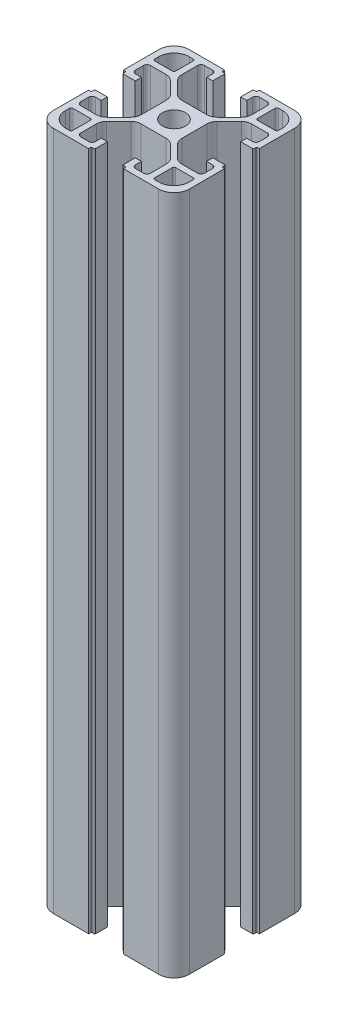
from build123d import *

# Parameters (mm, degrees)
BOSS_EXTRUDE1_DEPTH = 200


with BuildPart() as part:
    # Sketch1 → Boss-Extrude1 (new body)
    with BuildSketch(Plane(origin=(0, 0, 0), x_dir=(1, 0, 0), z_dir=(0, 1, 0))):
        with BuildLine():
            Line((84.170223908, 31.720417041), (84.170223908, 42.120417041))
            Line((84.170223908, 42.120417041), (83.570223908, 42.120417041))
            ThreePointArc((83.570223908, 42.120417041), (83.428802552, 42.178995685), (83.370223908, 42.320417041))
            Line((83.370223908, 42.320417041), (83.370223908, 42.920417041))
            ThreePointArc((83.370223908, 42.920417041), (83.311645264, 43.061838398), (83.170223908, 43.120417041))
            Line((83.170223908, 43.120417041), (79.670223908, 43.120417041))
            Line((79.670223908, 43.120417041), (79.670223908, 41.320417041))
            Line((79.670223908, 41.320417041), (81.370223908, 41.320417041))
            ThreePointArc((81.370223908, 41.320417041), (82.077330689, 41.027523823), (82.370223908, 40.320417041))
            Line((82.370223908, 40.320417041), (82.370223908, 37.970417041))
            ThreePointArc((82.370223908, 37.970417041), (82.077330689, 37.26331026), (81.370223908, 36.970417041))
            Line((81.370223908, 36.970417041), (76.723524767, 36.970417041))
            ThreePointArc((76.723524767, 36.970417041), (75.57547447, 37.198778444), (74.602204423, 37.849096698))
            Line((74.602204423, 37.849096698), (71.048903564, 41.402397557))
            ThreePointArc((71.048903564, 41.402397557), (70.39858531, 42.375667603), (70.170223908, 43.5237179))
            Line((70.170223908, 43.5237179), (70.170223908, 50.917116183))
            ThreePointArc((70.170223908, 50.917116183), (70.39858531, 52.06516648), (71.048903564, 53.038436526))
            Line((71.048903564, 53.038436526), (74.602204423, 56.591737385))
            ThreePointArc((74.602204423, 56.591737385), (75.57547447, 57.242055639), (76.723524767, 57.470417041))
            Line((76.723524767, 57.470417041), (81.370223908, 57.470417041))
            ThreePointArc((81.370223908, 57.470417041), (82.077330689, 57.177523823), (82.370223908, 56.470417041))
            Line((82.370223908, 56.470417041), (82.370223908, 54.120417041))
            ThreePointArc((82.370223908, 54.120417041), (82.077330689, 53.41331026), (81.370223908, 53.120417041))
            Line((81.370223908, 53.120417041), (79.670223908, 53.120417041))
            Line((79.670223908, 53.120417041), (79.670223908, 51.320417041))
            Line((79.670223908, 51.320417041), (83.170223908, 51.320417041))
            ThreePointArc((83.170223908, 51.320417041), (83.311645264, 51.378995685), (83.370223908, 51.520417041))
            Line((83.370223908, 51.520417041), (83.370223908, 52.120417041))
            ThreePointArc((83.370223908, 52.120417041), (83.428802552, 52.261838398), (83.570223908, 52.320417041))
            Line((83.570223908, 52.320417041), (84.170223908, 52.320417041))
            Line((84.170223908, 52.320417041), (84.170223908, 62.720417041))
            ThreePointArc((84.170223908, 62.720417041), (82.852204423, 65.902397557), (79.670223908, 67.220417041))
            Line((79.670223908, 67.220417041), (69.470223908, 67.220417041))
            ThreePointArc((69.470223908, 67.220417041), (69.328802552, 67.161838398), (69.270223908, 67.020417041))
            Line((69.270223908, 67.020417041), (69.270223908, 66.620417041))
            ThreePointArc((69.270223908, 66.620417041), (69.211645264, 66.478995685), (69.070223908, 66.420417041))
            Line((69.070223908, 66.420417041), (68.470223908, 66.420417041))
            ThreePointArc((68.470223908, 66.420417041), (68.328802552, 66.361838398), (68.270223908, 66.220417041))
            Line((68.270223908, 66.220417041), (68.270223908, 62.720417041))
            Line((68.270223908, 62.720417041), (70.070223908, 62.720417041))
            Line((70.070223908, 62.720417041), (70.070223908, 64.420417041))
            ThreePointArc((70.070223908, 64.420417041), (70.363117127, 65.127523823), (71.070223908, 65.420417041))
            Line((71.070223908, 65.420417041), (73.420223908, 65.420417041))
            ThreePointArc((73.420223908, 65.420417041), (74.127330689, 65.127523823), (74.420223908, 64.420417041))
            Line((74.420223908, 64.420417041), (74.420223908, 59.7737179))
            ThreePointArc((74.420223908, 59.7737179), (74.191862505, 58.625667603), (73.541544251, 57.652397557))
            Line((73.541544251, 57.652397557), (69.988243393, 54.099096698))
            ThreePointArc((69.988243393, 54.099096698), (69.014973346, 53.448778444), (67.866923049, 53.220417041))
            Line((67.866923049, 53.220417041), (60.473524767, 53.220417041))
            ThreePointArc((60.473524767, 53.220417041), (59.32547447, 53.448778444), (58.352204423, 54.099096698))
            Line((58.352204423, 54.099096698), (54.798903564, 57.652397557))
            ThreePointArc((54.798903564, 57.652397557), (54.14858531, 58.625667603), (53.920223908, 59.7737179))
            Line((53.920223908, 59.7737179), (53.920223908, 64.420417041))
            ThreePointArc((53.920223908, 64.420417041), (54.213117127, 65.127523823), (54.920223908, 65.420417041))
            Line((54.920223908, 65.420417041), (57.270223908, 65.420417041))
            ThreePointArc((57.270223908, 65.420417041), (57.977330689, 65.127523823), (58.270223908, 64.420417041))
            Line((58.270223908, 64.420417041), (58.270223908, 62.720417041))
            Line((58.270223908, 62.720417041), (60.070223908, 62.720417041))
            Line((60.070223908, 62.720417041), (60.070223908, 66.220417041))
            ThreePointArc((60.070223908, 66.220417041), (60.011645264, 66.361838398), (59.870223908, 66.420417041))
            Line((59.870223908, 66.420417041), (59.270223908, 66.420417041))
            ThreePointArc((59.270223908, 66.420417041), (59.128802552, 66.478995685), (59.070223908, 66.620417041))
            Line((59.070223908, 66.620417041), (59.070223908, 67.020417041))
            ThreePointArc((59.070223908, 67.020417041), (59.011645264, 67.161838398), (58.870223908, 67.220417041))
            Line((58.870223908, 67.220417041), (48.670223908, 67.220417041))
            ThreePointArc((48.670223908, 67.220417041), (45.488243393, 65.902397557), (44.170223908, 62.720417041))
            Line((44.170223908, 62.720417041), (44.170223908, 52.320417041))
            Line((44.170223908, 52.320417041), (44.770223908, 52.320417041))
            ThreePointArc((44.770223908, 52.320417041), (44.911645264, 52.261838398), (44.970223908, 52.120417041))
            Line((44.970223908, 52.120417041), (44.970223908, 51.520417041))
            ThreePointArc((44.970223908, 51.520417041), (45.028802552, 51.378995685), (45.170223908, 51.320417041))
            Line((45.170223908, 51.320417041), (48.670223908, 51.320417041))
            Line((48.670223908, 51.320417041), (48.670223908, 53.120417041))
            Line((48.670223908, 53.120417041), (46.970223908, 53.120417041))
            ThreePointArc((46.970223908, 53.120417041), (46.263117127, 53.41331026), (45.970223908, 54.120417041))
            Line((45.970223908, 54.120417041), (45.970223908, 56.470417041))
            ThreePointArc((45.970223908, 56.470417041), (46.263117127, 57.177523823), (46.970223908, 57.470417041))
            Line((46.970223908, 57.470417041), (51.616923049, 57.470417041))
            ThreePointArc((51.616923049, 57.470417041), (52.764973346, 57.242055639), (53.738243393, 56.591737385))
            Line((53.738243393, 56.591737385), (57.291544251, 53.038436526))
            ThreePointArc((57.291544251, 53.038436526), (57.941862505, 52.06516648), (58.170223908, 50.917116183))
            Line((58.170223908, 50.917116183), (58.170223908, 43.5237179))
            ThreePointArc((58.170223908, 43.5237179), (57.941862505, 42.375667603), (57.291544251, 41.402397557))
            Line((57.291544251, 41.402397557), (53.738243393, 37.849096698))
            ThreePointArc((53.738243393, 37.849096698), (52.764973346, 37.198778444), (51.616923049, 36.970417041))
            Line((51.616923049, 36.970417041), (46.970223908, 36.970417041))
            ThreePointArc((46.970223908, 36.970417041), (46.263117127, 37.26331026), (45.970223908, 37.970417041))
            Line((45.970223908, 37.970417041), (45.970223908, 40.320417041))
            ThreePointArc((45.970223908, 40.320417041), (46.263117127, 41.027523823), (46.970223908, 41.320417041))
            Line((46.970223908, 41.320417041), (48.670223908, 41.320417041))
            Line((48.670223908, 41.320417041), (48.670223908, 43.120417041))
            Line((48.670223908, 43.120417041), (45.170223908, 43.120417041))
            ThreePointArc((45.170223908, 43.120417041), (45.028802552, 43.061838398), (44.970223908, 42.920417041))
            Line((44.970223908, 42.920417041), (44.970223908, 42.320417041))
            ThreePointArc((44.970223908, 42.320417041), (44.911645264, 42.178995685), (44.770223908, 42.120417041))
            Line((44.770223908, 42.120417041), (44.170223908, 42.120417041))
            Line((44.170223908, 42.120417041), (44.170223908, 31.720417041))
            ThreePointArc((44.170223908, 31.720417041), (45.488243393, 28.538436526), (48.670223908, 27.220417041))
            Line((48.670223908, 27.220417041), (59.070223908, 27.220417041))
            Line((59.070223908, 27.220417041), (59.070223908, 27.820417041))
            ThreePointArc((59.070223908, 27.820417041), (59.128802552, 27.961838398), (59.270223908, 28.020417041))
            Line((59.270223908, 28.020417041), (59.870223908, 28.020417041))
            ThreePointArc((59.870223908, 28.020417041), (60.011645264, 28.078995685), (60.070223908, 28.220417041))
            Line((60.070223908, 28.220417041), (60.070223908, 31.720417041))
            Line((60.070223908, 31.720417041), (58.270223908, 31.720417041))
            Line((58.270223908, 31.720417041), (58.270223908, 30.020417041))
            ThreePointArc((58.270223908, 30.020417041), (57.977330689, 29.31331026), (57.270223908, 29.020417041))
            Line((57.270223908, 29.020417041), (54.920223908, 29.020417041))
            ThreePointArc((54.920223908, 29.020417041), (54.213117127, 29.31331026), (53.920223908, 30.020417041))
            Line((53.920223908, 30.020417041), (53.920223908, 34.667116183))
            ThreePointArc((53.920223908, 34.667116183), (54.14858531, 35.81516648), (54.798903564, 36.788436526))
            Line((54.798903564, 36.788436526), (58.352204423, 40.341737385))
            ThreePointArc((58.352204423, 40.341737385), (59.32547447, 40.992055639), (60.473524767, 41.220417041))
            Line((60.473524767, 41.220417041), (67.866923049, 41.220417041))
            ThreePointArc((67.866923049, 41.220417041), (69.014973346, 40.992055639), (69.988243393, 40.341737385))
            Line((69.988243393, 40.341737385), (73.541544251, 36.788436526))
            ThreePointArc((73.541544251, 36.788436526), (74.191862505, 35.81516648), (74.420223908, 34.667116183))
            Line((74.420223908, 34.667116183), (74.420223908, 30.020417041))
            ThreePointArc((74.420223908, 30.020417041), (74.127330689, 29.31331026), (73.420223908, 29.020417041))
            Line((73.420223908, 29.020417041), (71.070223908, 29.020417041))
            ThreePointArc((71.070223908, 29.020417041), (70.363117127, 29.31331026), (70.070223908, 30.020417041))
            Line((70.070223908, 30.020417041), (70.070223908, 31.720417041))
            Line((70.070223908, 31.720417041), (68.270223908, 31.720417041))
            Line((68.270223908, 31.720417041), (68.270223908, 28.220417041))
            ThreePointArc((68.270223908, 28.220417041), (68.328802552, 28.078995685), (68.470223908, 28.020417041))
            Line((68.470223908, 28.020417041), (69.070223908, 28.020417041))
            ThreePointArc((69.070223908, 28.020417041), (69.211645264, 27.961838398), (69.270223908, 27.820417041))
            Line((69.270223908, 27.820417041), (69.270223908, 27.220417041))
            Line((69.270223908, 27.220417041), (79.670223908, 27.220417041))
            ThreePointArc((79.670223908, 27.220417041), (82.852204423, 28.538436526), (84.170223908, 31.720417041))
        make_face()
        with BuildLine():
            Line((82.370223908, 34.670417041), (82.370223908, 33.520417041))
            ThreePointArc((82.370223908, 33.520417041), (81.052204423, 30.338436526), (77.870223908, 29.020417041))
            Line((77.870223908, 29.020417041), (76.720223908, 29.020417041))
            ThreePointArc((76.720223908, 29.020417041), (76.366670517, 29.166863651), (76.220223908, 29.520417041))
            Line((76.220223908, 29.520417041), (76.220223908, 34.670417041))
            ThreePointArc((76.220223908, 34.670417041), (76.366670517, 35.023970432), (76.720223908, 35.170417041))
            Line((76.720223908, 35.170417041), (81.870223908, 35.170417041))
            ThreePointArc((81.870223908, 35.170417041), (82.223777298, 35.023970432), (82.370223908, 34.670417041))
        make_face(mode=Mode.SUBTRACT)
        with BuildLine():
            Line((51.620223908, 29.020417041), (50.470223908, 29.020417041))
            ThreePointArc((50.470223908, 29.020417041), (47.288243393, 30.338436526), (45.970223908, 33.520417041))
            Line((45.970223908, 33.520417041), (45.970223908, 34.670417041))
            ThreePointArc((45.970223908, 34.670417041), (46.116670517, 35.023970432), (46.470223908, 35.170417041))
            Line((46.470223908, 35.170417041), (51.620223908, 35.170417041))
            ThreePointArc((51.620223908, 35.170417041), (51.973777298, 35.023970432), (52.120223908, 34.670417041))
            Line((52.120223908, 34.670417041), (52.120223908, 29.520417041))
            ThreePointArc((52.120223908, 29.520417041), (51.973777298, 29.166863651), (51.620223908, 29.020417041))
        make_face(mode=Mode.SUBTRACT)
        with BuildLine():
            Line((45.970223908, 59.770417041), (45.970223908, 60.920417041))
            ThreePointArc((45.970223908, 60.920417041), (47.288243393, 64.102397557), (50.470223908, 65.420417041))
            Line((50.470223908, 65.420417041), (51.620223908, 65.420417041))
            ThreePointArc((51.620223908, 65.420417041), (51.973777298, 65.273970432), (52.120223908, 64.920417041))
            Line((52.120223908, 64.920417041), (52.120223908, 59.770417041))
            ThreePointArc((52.120223908, 59.770417041), (51.973777298, 59.416863651), (51.620223908, 59.270417041))
            Line((51.620223908, 59.270417041), (46.470223908, 59.270417041))
            ThreePointArc((46.470223908, 59.270417041), (46.116670517, 59.416863651), (45.970223908, 59.770417041))
        make_face(mode=Mode.SUBTRACT)
        with BuildLine():
            Line((76.720223908, 65.420417041), (77.870223908, 65.420417041))
            ThreePointArc((77.870223908, 65.420417041), (81.052204423, 64.102397557), (82.370223908, 60.920417041))
            Line((82.370223908, 60.920417041), (82.370223908, 59.770417041))
            ThreePointArc((82.370223908, 59.770417041), (82.223777298, 59.416863651), (81.870223908, 59.270417041))
            Line((81.870223908, 59.270417041), (76.720223908, 59.270417041))
            ThreePointArc((76.720223908, 59.270417041), (76.366670517, 59.416863651), (76.220223908, 59.770417041))
            Line((76.220223908, 59.770417041), (76.220223908, 64.920417041))
            ThreePointArc((76.220223908, 64.920417041), (76.366670517, 65.273970432), (76.720223908, 65.420417041))
        make_face(mode=Mode.SUBTRACT)
        with BuildLine():
            ThreePointArc((60.770223908, 47.220417041), (64.170223908, 43.820417041), (67.570223908, 47.220417041))
            ThreePointArc((67.570223908, 47.220417041), (64.170223908, 50.620417041), (60.770223908, 47.220417041))
        make_face(mode=Mode.SUBTRACT)
    extrude(amount=BOSS_EXTRUDE1_DEPTH)


solid = part.part
